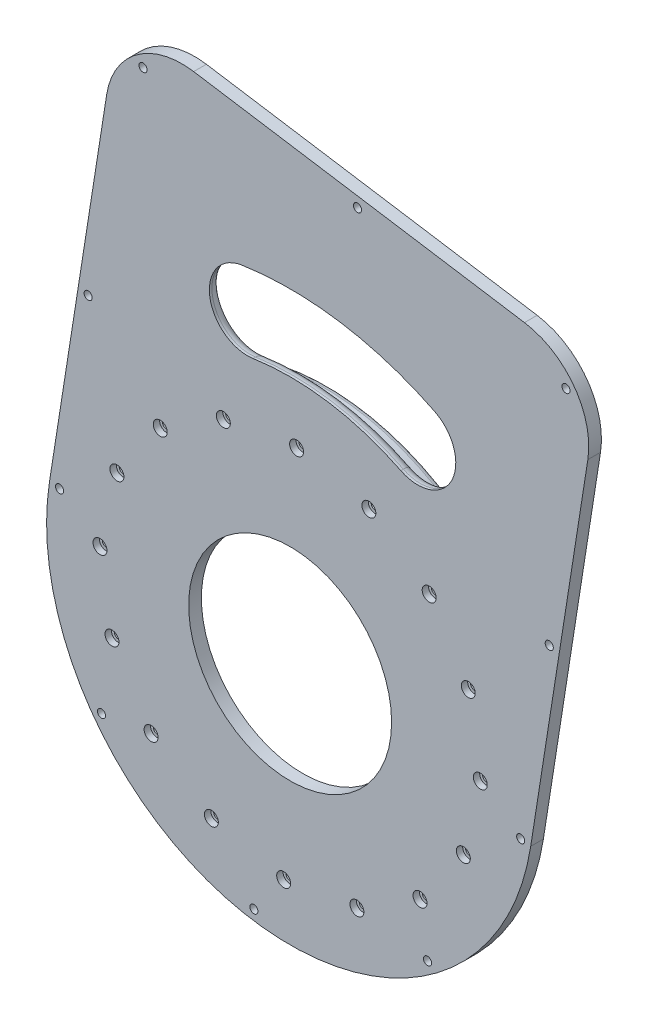
from build123d import *

# Parameters (mm, degrees)
BOSS_EXTRUDE1_START = -10
SKETCH1_R           = 88
SKETCH1_R_2         = 84
BOSS_EXTRUDE1_DEPTH = 14
BOSS_EXTRUDE2_START = -4
SKETCH2_R           = 40
BOSS_EXTRUDE2_DEPTH = 5
CUT_EXTRUDE1_REACH  = 7
SKETCH3_R           = 1.6
FILLET1_R           = 30
SKETCH4_R           = 2.75
CUT_EXTRUDE2_DEPTH  = 2.5
FILLET2_R           = 2
FILLET3_R           = 2
SKETCH5_R           = 1.6
CUT_EXTRUDE3_DEPTH  = 16
CUT_EXTRUDE4_START  = -2.5
SKETCH6_R           = 2.775
CUT_EXTRUDE4_DEPTH  = 2.65626
FILLET4_R           = 4


with BuildPart() as part:
    # Sketch1 → Boss-Extrude1 (new body)
    with BuildSketch(Plane.XY.offset(BOSS_EXTRUDE1_START)):
        with Locations((20.142161583, -37.124408079)):
            Circle(SKETCH1_R)
        with Locations((20.142161583, -37.124408079)):
            Circle(SKETCH1_R_2, mode=Mode.SUBTRACT)
    extrude(amount=BOSS_EXTRUDE1_DEPTH)

    # Sketch2 → Boss-Extrude2 (add)
    with BuildSketch(Plane.XY.offset(4).offset(BOSS_EXTRUDE2_START)):
        with BuildLine():
            Line((-74.693413886, -22.217576581), (-47.515501186, 150.685229173))
            Line((-47.515501186, 150.685229173), (142.155649753, 120.871566176))
            Line((142.155649753, 120.871566176), (114.977737053, -52.031239578))
            ThreePointArc((114.977737053, -52.031239578), (5.235330085, -131.959983549), (-74.693413886, -22.217576581))
        make_face()
        with Locations((20.142161583, -37.124408079)):
            Circle(SKETCH2_R, mode=Mode.SUBTRACT)
        with BuildLine():
            ThreePointArc((63.766969205, 50.630228038), (35.359552071, 59.686908546), (5.543520471, 59.782143184))
            ThreePointArc((5.543520471, 59.782143184), (-11.523600811, 72.380292697), (1.074548702, 89.447413979))
            ThreePointArc((1.074548702, 89.447413979), (40.017936915, 89.32302588), (77.12150215, 77.493892155))
            ThreePointArc((77.12150215, 77.493892155), (83.876067736, 57.384793624), (63.766969205, 50.630228038))
        make_face(mode=Mode.SUBTRACT)
    extrude(amount=BOSS_EXTRUDE2_DEPTH)

    # Sketch3 → Cut-Extrude1 (cut, up to next)
    with BuildSketch(Plane(origin=(0, 0, 0), x_dir=(-1, 0, 0), z_dir=(0, 0, -1)), mode=Mode.PRIVATE) as cut_extrude1_sk1:
        with Locations((31.057216555, 17.680917193)):
            Circle(SKETCH3_R)
    cut_extrude1_tool1 = extrude(cut_extrude1_sk1.sketch, amount=-CUT_EXTRUDE1_REACH, mode=Mode.PRIVATE) & part.part
    add(cut_extrude1_tool1.solids().sort_by_distance((-31.057217, 17.680917, 0))[0], mode=Mode.SUBTRACT)
    # Sketch3 → Cut-Extrude1 (cut, up to next)
    with BuildSketch(Plane(origin=(0, 0, 0), x_dir=(-1, 0, 0), z_dir=(0, 0, -1)), mode=Mode.PRIVATE) as cut_extrude1_sk2:
        with Locations((48.132985943, -6.084043548)):
            Circle(SKETCH3_R)
    cut_extrude1_tool2 = extrude(cut_extrude1_sk2.sketch, amount=-CUT_EXTRUDE1_REACH, mode=Mode.PRIVATE) & part.part
    add(cut_extrude1_tool2.solids().sort_by_distance((-48.132986, -6.084044, 0))[0], mode=Mode.SUBTRACT)
    # Sketch3 → Cut-Extrude1 (cut, up to next)
    with BuildSketch(Plane(origin=(0, 0, 0), x_dir=(-1, 0, 0), z_dir=(0, 0, -1)), mode=Mode.PRIVATE) as cut_extrude1_sk3:
        with Locations((54.814483036, -34.574618408)):
            Circle(SKETCH3_R)
    cut_extrude1_tool3 = extrude(cut_extrude1_sk3.sketch, amount=-CUT_EXTRUDE1_REACH, mode=Mode.PRIVATE) & part.part
    add(cut_extrude1_tool3.solids().sort_by_distance((-54.814483, -34.574618, 0))[0], mode=Mode.SUBTRACT)
    # Sketch3 → Cut-Extrude1 (cut, up to next)
    with BuildSketch(Plane(origin=(0, 0, 0), x_dir=(-1, 0, 0), z_dir=(0, 0, -1)), mode=Mode.PRIVATE) as cut_extrude1_sk4:
        with Locations((50.084510469, -63.453375632)):
            Circle(SKETCH3_R)
    cut_extrude1_tool4 = extrude(cut_extrude1_sk4.sketch, amount=-CUT_EXTRUDE1_REACH, mode=Mode.PRIVATE) & part.part
    add(cut_extrude1_tool4.solids().sort_by_distance((-50.08451, -63.453376, 0))[0], mode=Mode.SUBTRACT)
    # Sketch3 → Cut-Extrude1 (cut, up to next)
    with BuildSketch(Plane(origin=(0, 0, 0), x_dir=(-1, 0, 0), z_dir=(0, 0, -1)), mode=Mode.PRIVATE) as cut_extrude1_sk5:
        with Locations((34.663163689, -88.323786218)):
            Circle(SKETCH3_R)
    cut_extrude1_tool5 = extrude(cut_extrude1_sk5.sketch, amount=-CUT_EXTRUDE1_REACH, mode=Mode.PRIVATE) & part.part
    add(cut_extrude1_tool5.solids().sort_by_distance((-34.663164, -88.323786, 0))[0], mode=Mode.SUBTRACT)
    # Sketch3 → Cut-Extrude1 (cut, up to next)
    with BuildSketch(Plane(origin=(0, 0, 0), x_dir=(-1, 0, 0), z_dir=(0, 0, -1)), mode=Mode.PRIVATE) as cut_extrude1_sk6:
        with Locations((10.898202947, -105.399555606)):
            Circle(SKETCH3_R)
    cut_extrude1_tool6 = extrude(cut_extrude1_sk6.sketch, amount=-CUT_EXTRUDE1_REACH, mode=Mode.PRIVATE) & part.part
    add(cut_extrude1_tool6.solids().sort_by_distance((-10.898203, -105.399556, 0))[0], mode=Mode.SUBTRACT)
    # Sketch3 → Cut-Extrude1 (cut, up to next)
    with BuildSketch(Plane(origin=(0, 0, 0), x_dir=(-1, 0, 0), z_dir=(0, 0, -1)), mode=Mode.PRIVATE) as cut_extrude1_sk7:
        with Locations((-17.592371912, -112.081052699)):
            Circle(SKETCH3_R)
    cut_extrude1_tool7 = extrude(cut_extrude1_sk7.sketch, amount=-CUT_EXTRUDE1_REACH, mode=Mode.PRIVATE) & part.part
    add(cut_extrude1_tool7.solids().sort_by_distance((17.592372, -112.081053, 0))[0], mode=Mode.SUBTRACT)
    # Sketch3 → Cut-Extrude1 (cut, up to next)
    with BuildSketch(Plane(origin=(0, 0, 0), x_dir=(-1, 0, 0), z_dir=(0, 0, -1)), mode=Mode.PRIVATE) as cut_extrude1_sk8:
        with Locations((-46.471129136, -107.351080132)):
            Circle(SKETCH3_R)
    cut_extrude1_tool8 = extrude(cut_extrude1_sk8.sketch, amount=-CUT_EXTRUDE1_REACH, mode=Mode.PRIVATE) & part.part
    add(cut_extrude1_tool8.solids().sort_by_distance((46.471129, -107.35108, 0))[0], mode=Mode.SUBTRACT)
    # Sketch3 → Cut-Extrude1 (cut, up to next)
    with BuildSketch(Plane(origin=(0, 0, 0), x_dir=(-1, 0, 0), z_dir=(0, 0, -1)), mode=Mode.PRIVATE) as cut_extrude1_sk9:
        with Locations((-71.341539722, -91.929733352)):
            Circle(SKETCH3_R)
    cut_extrude1_tool9 = extrude(cut_extrude1_sk9.sketch, amount=-CUT_EXTRUDE1_REACH, mode=Mode.PRIVATE) & part.part
    add(cut_extrude1_tool9.solids().sort_by_distance((71.34154, -91.929733, 0))[0], mode=Mode.SUBTRACT)
    # Sketch3 → Cut-Extrude1 (cut, up to next)
    with BuildSketch(Plane(origin=(0, 0, 0), x_dir=(-1, 0, 0), z_dir=(0, 0, -1)), mode=Mode.PRIVATE) as cut_extrude1_sk10:
        with Locations((-88.41730911, -68.16477261)):
            Circle(SKETCH3_R)
    cut_extrude1_tool10 = extrude(cut_extrude1_sk10.sketch, amount=-CUT_EXTRUDE1_REACH, mode=Mode.PRIVATE) & part.part
    add(cut_extrude1_tool10.solids().sort_by_distance((88.417309, -68.164773, 0))[0], mode=Mode.SUBTRACT)
    # Sketch3 → Cut-Extrude1 (cut, up to next)
    with BuildSketch(Plane(origin=(0, 0, 0), x_dir=(-1, 0, 0), z_dir=(0, 0, -1)), mode=Mode.PRIVATE) as cut_extrude1_sk11:
        with Locations((-95.098806203, -39.67419775)):
            Circle(SKETCH3_R)
    cut_extrude1_tool11 = extrude(cut_extrude1_sk11.sketch, amount=-CUT_EXTRUDE1_REACH, mode=Mode.PRIVATE) & part.part
    add(cut_extrude1_tool11.solids().sort_by_distance((95.098806, -39.674198, 0))[0], mode=Mode.SUBTRACT)
    # Sketch3 → Cut-Extrude1 (cut, up to next)
    with BuildSketch(Plane(origin=(0, 0, 0), x_dir=(-1, 0, 0), z_dir=(0, 0, -1)), mode=Mode.PRIVATE) as cut_extrude1_sk12:
        with Locations((-90.368833636, -10.795440527)):
            Circle(SKETCH3_R)
    cut_extrude1_tool12 = extrude(cut_extrude1_sk12.sketch, amount=-CUT_EXTRUDE1_REACH, mode=Mode.PRIVATE) & part.part
    add(cut_extrude1_tool12.solids().sort_by_distance((90.368834, -10.795441, 0))[0], mode=Mode.SUBTRACT)
    # Sketch3 → Cut-Extrude1 (cut, up to next)
    with BuildSketch(Plane(origin=(0, 0, 0), x_dir=(-1, 0, 0), z_dir=(0, 0, -1)), mode=Mode.PRIVATE) as cut_extrude1_sk13:
        with Locations((-74.947486856, 14.074970059)):
            Circle(SKETCH3_R)
    cut_extrude1_tool13 = extrude(cut_extrude1_sk13.sketch, amount=-CUT_EXTRUDE1_REACH, mode=Mode.PRIVATE) & part.part
    add(cut_extrude1_tool13.solids().sort_by_distance((74.947487, 14.07497, 0))[0], mode=Mode.SUBTRACT)
    # Sketch3 → Cut-Extrude1 (cut, up to next)
    with BuildSketch(Plane(origin=(0, 0, 0), x_dir=(-1, 0, 0), z_dir=(0, 0, -1)), mode=Mode.PRIVATE) as cut_extrude1_sk14:
        with Locations((-51.182526114, 31.150739448)):
            Circle(SKETCH3_R)
    cut_extrude1_tool14 = extrude(cut_extrude1_sk14.sketch, amount=-CUT_EXTRUDE1_REACH, mode=Mode.PRIVATE) & part.part
    add(cut_extrude1_tool14.solids().sort_by_distance((51.182526, 31.150739, 0))[0], mode=Mode.SUBTRACT)
    # Sketch3 → Cut-Extrude1 (cut, up to next)
    with BuildSketch(Plane(origin=(0, 0, 0), x_dir=(-1, 0, 0), z_dir=(0, 0, -1)), mode=Mode.PRIVATE) as cut_extrude1_sk15:
        with Locations((-22.691951254, 37.83223654)):
            Circle(SKETCH3_R)
    cut_extrude1_tool15 = extrude(cut_extrude1_sk15.sketch, amount=-CUT_EXTRUDE1_REACH, mode=Mode.PRIVATE) & part.part
    add(cut_extrude1_tool15.solids().sort_by_distance((22.691951, 37.832237, 0))[0], mode=Mode.SUBTRACT)
    # Sketch3 → Cut-Extrude1 (cut, up to next)
    with BuildSketch(Plane(origin=(0, 0, 0), x_dir=(-1, 0, 0), z_dir=(0, 0, -1)), mode=Mode.PRIVATE) as cut_extrude1_sk16:
        with Locations((6.186805969, 33.102263974)):
            Circle(SKETCH3_R)
    cut_extrude1_tool16 = extrude(cut_extrude1_sk16.sketch, amount=-CUT_EXTRUDE1_REACH, mode=Mode.PRIVATE) & part.part
    add(cut_extrude1_tool16.solids().sort_by_distance((-6.186806, 33.102264, 0))[0], mode=Mode.SUBTRACT)

    # Fillet1
    fillet1_edges = [part.edges().sort_by_distance(p)[0] for p in [
        (142.155649753, 120.871566176, 2.5),
        (-47.515501186, 150.685229173, 2.5),
    ]]
    fillet(fillet1_edges, radius=FILLET1_R)

    # Sketch4 → Cut-Extrude2 (cut)
    with BuildSketch(Plane.XY.offset(5)):
        with Locations((90.368833636, -10.795440527)):
            Circle(SKETCH4_R)
        with Locations((95.098806203, -39.67419775)):
            Circle(SKETCH4_R)
        with Locations((88.41730911, -68.16477261)):
            Circle(SKETCH4_R)
        with Locations((71.341539722, -91.929733352)):
            Circle(SKETCH4_R)
        with Locations((46.471129136, -107.351080132)):
            Circle(SKETCH4_R)
        with Locations((17.592371912, -112.081052699)):
            Circle(SKETCH4_R)
        with Locations((-10.898202947, -105.399555606)):
            Circle(SKETCH4_R)
        with Locations((-34.663163689, -88.323786218)):
            Circle(SKETCH4_R)
        with Locations((-50.084510469, -63.453375632)):
            Circle(SKETCH4_R)
        with Locations((-54.814483036, -34.574618408)):
            Circle(SKETCH4_R)
        with Locations((-48.132985943, -6.084043548)):
            Circle(SKETCH4_R)
        with Locations((-31.057216555, 17.680917193)):
            Circle(SKETCH4_R)
        with Locations((-6.186805969, 33.102263974)):
            Circle(SKETCH4_R)
        with Locations((22.691951254, 37.83223654)):
            Circle(SKETCH4_R)
        with Locations((51.182526114, 31.150739448)):
            Circle(SKETCH4_R)
        with Locations((74.947486856, 14.074970059)):
            Circle(SKETCH4_R)
    extrude(amount=-CUT_EXTRUDE2_DEPTH, mode=Mode.SUBTRACT)

    # Fillet2
    fillet2_edges = [part.edges().sort_by_distance(p)[0] for p in [
        (-67.857838417, -37.124408079, 0),
    ]]
    fillet(fillet2_edges, radius=FILLET2_R)

    # Fillet3
    fillet3_edges = [part.edges().sort_by_distance(p)[0] for p in [
        (-67.857838417, -37.124408079, -10),
    ]]
    fillet(fillet3_edges, radius=FILLET3_R)

    # Sketch5 → Cut-Extrude3 (cut, through all)
    with BuildSketch(Plane.XY.offset(5)):
        with Locations((128.87770595, 111.200834505)):
            Circle(SKETCH5_R)
        with Locations((122.286018677, 20.223222655)):
            Circle(SKETCH5_R)
        with Locations((111.026254756, -51.410121511)):
            Circle(SKETCH5_R)
        with Locations((74.305395326, -111.490691505)):
            Circle(SKETCH5_R)
        with Locations((5.856448152, -128.008501251)):
            Circle(SKETCH5_R)
        with Locations((-54.224121842, -91.287641822)):
            Circle(SKETCH5_R)
        with Locations((-70.741931589, -22.838694648)):
            Circle(SKETCH5_R)
        with Locations((-59.482167654, 48.794649604)):
            Circle(SKETCH5_R)
        with Locations((-37.844769515, 137.407285369)):
            Circle(SKETCH5_R)
        with Locations((46.698956131, 131.826915326)):
            Circle(SKETCH5_R)
    extrude(amount=-CUT_EXTRUDE3_DEPTH, mode=Mode.SUBTRACT)

    # Sketch6 → Cut-Extrude4 (cut)
    with BuildSketch(Plane(origin=(0, 0, 0), x_dir=(-1, 0, 0), z_dir=(0, 0, -1)).offset(CUT_EXTRUDE4_START)):
        with Locations((-128.87770595, 111.200834505)):
            Circle(SKETCH6_R)
        with Locations((-46.698956131, 131.826915326)):
            Circle(SKETCH6_R)
        with Locations((37.844769515, 137.407285369)):
            Circle(SKETCH6_R)
        with Locations((59.482167654, 48.794649604)):
            Circle(SKETCH6_R)
        with Locations((70.741931589, -22.838694648)):
            Circle(SKETCH6_R)
        with Locations((54.224121842, -91.287641822)):
            Circle(SKETCH6_R)
        with Locations((-5.856448152, -128.008501251)):
            Circle(SKETCH6_R)
        with Locations((-74.305395326, -111.490691505)):
            Circle(SKETCH6_R)
        with Locations((-111.026254756, -51.410121511)):
            Circle(SKETCH6_R)
        with Locations((-122.286018677, 20.223222655)):
            Circle(SKETCH6_R)
    extrude(amount=CUT_EXTRUDE4_DEPTH, mode=Mode.SUBTRACT)

    # Fillet4
    fillet4_edges = [part.edges().sort_by_distance(p)[0] for p in [
        (40.017936915, 89.32302588, 0),
        (-11.523600811, 72.380292697, 0),
        (35.359552071, 59.686908546, 0),
        (83.876067736, 57.384793624, 0),
    ]]
    fillet(fillet4_edges, radius=FILLET4_R)


solid = part.part
